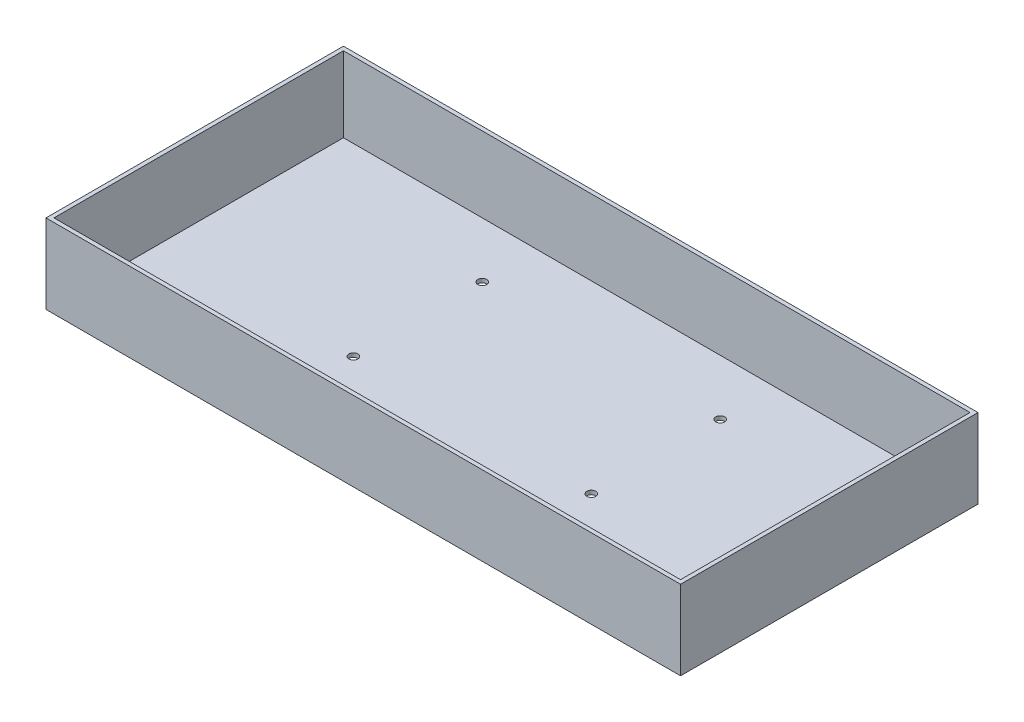
from build123d import *

# Parameters (mm, degrees)
SKETCH_1_W          = 320
SKETCH_1_H          = 150
EXTRUDE_1_DEPTH     = 40
SHELL_1_T           = -2
SKETCH_2_R          = 2.25
CUT_EXTRUDE_1_DEPTH = 2


with BuildPart() as part:
    # 草图1 → 凸台-拉伸1 (new body)
    with BuildSketch(Plane(origin=(0, 0, 0), x_dir=(1, 0, 0), z_dir=(0, 1, 0))):
        with Locations((160, 75)):
            Rectangle(SKETCH_1_W, SKETCH_1_H)
    extrude(amount=EXTRUDE_1_DEPTH)

    # 抽壳1
    shell_1_openings = [part.faces().sort_by_distance(p)[0] for p in [
        (160, 40, -75),
    ]]
    offset(amount=SHELL_1_T, openings=shell_1_openings, kind=Kind.INTERSECTION)

    # 草图2 → 切除-拉伸1 (cut)
    with BuildSketch(Plane(origin=(0, 0, 0), x_dir=(-1, 0, 0), z_dir=(0, -1, 0))):
        with Locations((-100, 55)):
            Circle(SKETCH_2_R)
        with Locations((-220, 55)):
            Circle(SKETCH_2_R)
        with Locations((-220, 120)):
            Circle(SKETCH_2_R)
        with Locations((-100, 120)):
            Circle(SKETCH_2_R)
    extrude(amount=-CUT_EXTRUDE_1_DEPTH, mode=Mode.SUBTRACT)


solid = part.part
